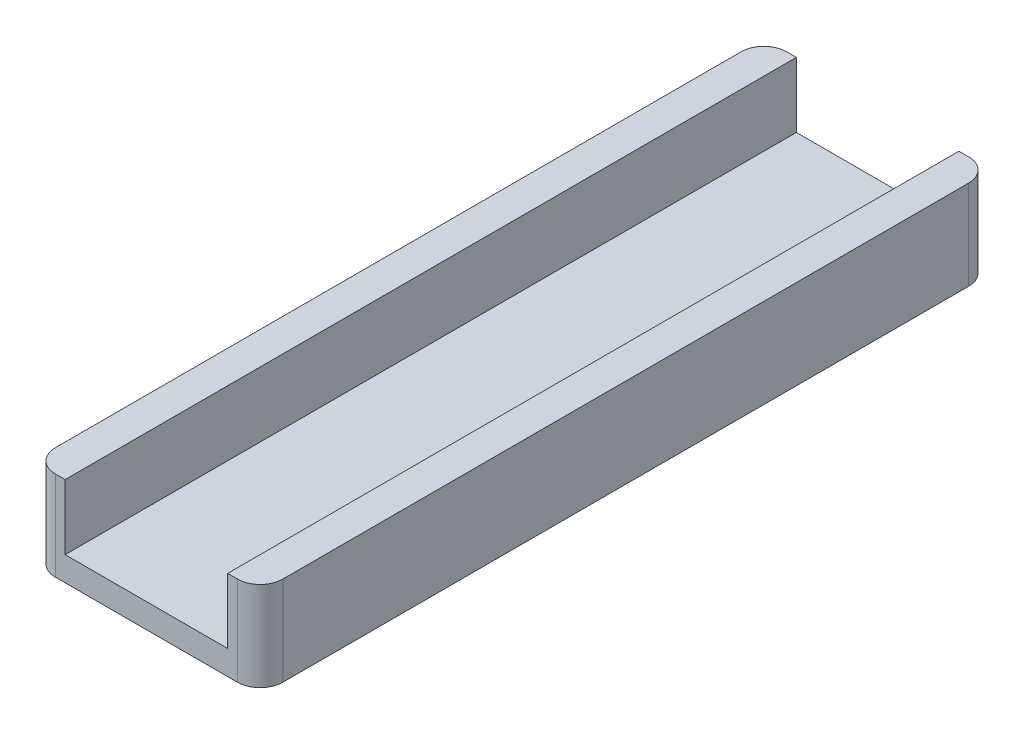
from build123d import *

# Parameters (mm, degrees)
SKETCH_1_W      = 14
SKETCH_1_H      = 45
EXTRUDE_1_DEPTH = 1.5
SKETCH_2_W      = 2
SKETCH_2_H      = 45
EXTRUDE_2_DEPTH = 4
FILLET_1_R      = 1.4


with BuildPart() as part:
    # 草图1 → 凸台-拉伸1 (new body)
    with BuildSketch(Plane(origin=(0, 0, 0), x_dir=(1, 0, 0), z_dir=(0, 1, 0))):
        with Locations((7, 22.5)):
            Rectangle(SKETCH_1_W, SKETCH_1_H)
    extrude(amount=EXTRUDE_1_DEPTH)

    # 草图2 → 凸台-拉伸2 (add)
    with BuildSketch(Plane(origin=(0, 1.5, 0), x_dir=(1, 0, 0), z_dir=(0, 1, 0))):
        with Locations((1, 22.5)):
            Rectangle(SKETCH_2_W, SKETCH_2_H)
        with Locations((13, 22.5)):
            Rectangle(SKETCH_2_W, SKETCH_2_H)
    extrude(amount=EXTRUDE_2_DEPTH)

    # 圆角1
    fillet_1_edges = [part.edges().sort_by_distance(p)[0] for p in [
        (0, 2.75, -45),
        (14, 2.75, -45),
        (14, 2.75, 0),
        (0, 2.75, 0),
    ]]
    fillet(fillet_1_edges, radius=FILLET_1_R)


solid = part.part
